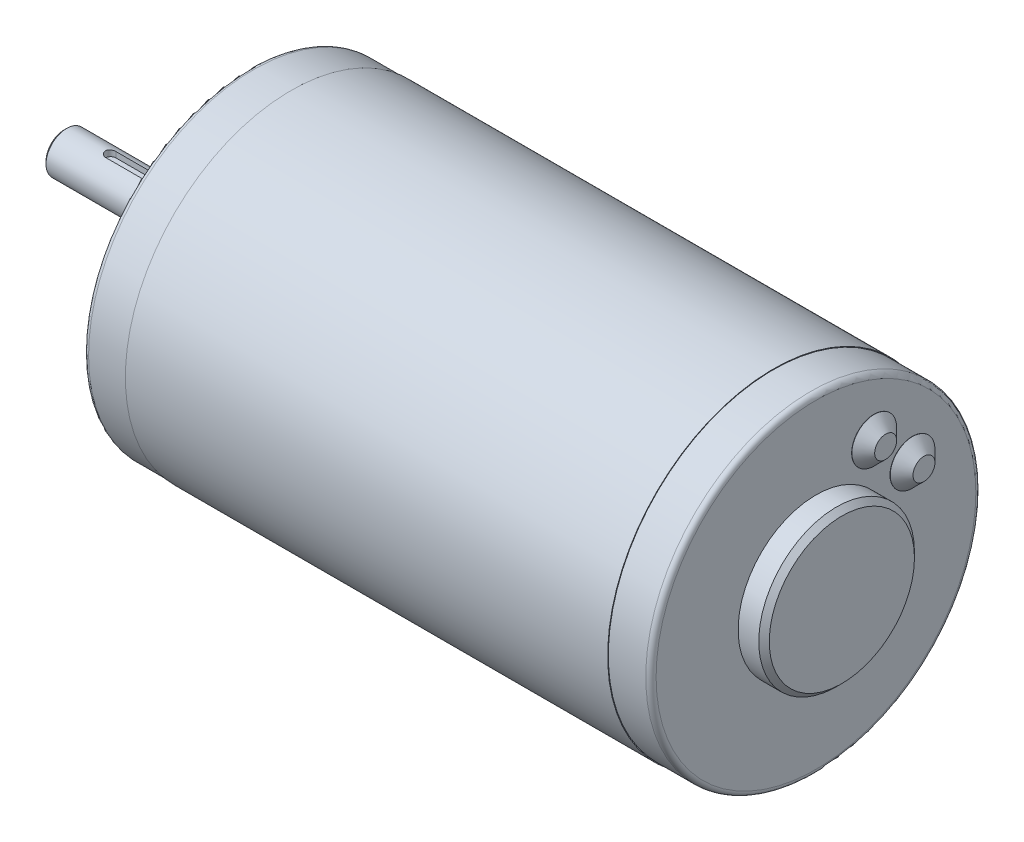
from build123d import *

# Parameters (mm, degrees)
SKETCH1_W                  = 93.1408
SKETCH1_H                  = 32.004
SKETCH2_R                  = 31.877
BOSS_EXTRUDE1_DEPTH        = 8.2296
SKETCH3_R                  = 15.0368
BOSS_EXTRUDE2_DEPTH        = 3.984
SKETCH4_R                  = 15.0368
BOSS_EXTRUDE3_DEPTH        = 1.016
BOSS_EXTRUDE3_TAPER        = 45
SKETCH5_R                  = 31.877
BOSS_EXTRUDE4_DEPTH        = 8.2296
SKETCH6_R                  = 9.525
BOSS_EXTRUDE5_DEPTH        = 4
SKETCH7_R                  = 4
BOSS_EXTRUDE6_DEPTH        = 31.6
CUT_EXTRUDE1_REACH         = 31.204
M3_5_CLEARANCE_HOLE1_D     = 4.0386
M3_5_CLEARANCE_HOLE1_DEPTH = 13.6144
M3_5_CLEARANCE_HOLE1_TIP   = 1.213317848
CHAMFER1_SIZE              = 1.016
CHAMFER2_SIZE              = 0.5
FILLET1_R                  = 1


with BuildPart() as part:
    # Sketch1 → Revolve1 (revolve)
    with BuildSketch(Plane.XY):
        with Locations((54.8, 16.002)):
            Rectangle(SKETCH1_W, SKETCH1_H)
    revolve(axis=Axis((8.2296, 0, 0), (1, 0, 0)))

    # Sketch2 → Boss-Extrude1 (add)
    with BuildSketch(Plane(origin=(101.3704, 0, 0), x_dir=(0, 0, -1), z_dir=(1, 0, 0))):
        Circle(SKETCH2_R)
    extrude(amount=BOSS_EXTRUDE1_DEPTH)

    # Sketch3 → Boss-Extrude2 (add)
    with BuildSketch(Plane(origin=(109.6, 0, 0), x_dir=(0, 0, -1), z_dir=(1, 0, 0))):
        Circle(SKETCH3_R)
    extrude(amount=BOSS_EXTRUDE2_DEPTH)

    # Sketch4 → Boss-Extrude3 (add)
    with BuildSketch(Plane(origin=(113.584, 0, 0), x_dir=(0, 0, -1), z_dir=(1, 0, 0))):
        Circle(SKETCH4_R)
    extrude(amount=BOSS_EXTRUDE3_DEPTH, taper=BOSS_EXTRUDE3_TAPER)

    # Sketch5 → Boss-Extrude4 (add)
    with BuildSketch(Plane.ZY.offset(-8.2296)):
        Circle(SKETCH5_R)
    extrude(amount=BOSS_EXTRUDE4_DEPTH)

    # Sketch6 → Boss-Extrude5 (add)
    with BuildSketch(Plane.ZY):
        Circle(SKETCH6_R)
    extrude(amount=BOSS_EXTRUDE5_DEPTH)

    # Sketch7 → Boss-Extrude6 (add)
    with BuildSketch(Plane.ZY.offset(4)):
        Circle(SKETCH7_R)
    extrude(amount=BOSS_EXTRUDE6_DEPTH)

    # Sketch8 → Cut-Extrude1 (cut, up to next)
    with BuildSketch(Plane.XZ.offset(-2.8), mode=Mode.PRIVATE) as cut_extrude1_sk1:
        with BuildLine():
            Line((-7.1, 1), (-26.6, 1))
            ThreePointArc((-26.6, 1), (-27.6, 0), (-26.6, -1))
            Line((-26.6, -1), (-7.1, -1))
            ThreePointArc((-7.1, -1), (-6.1, 0), (-7.1, 1))
        make_face()
    cut_extrude1_tool1 = extrude(cut_extrude1_sk1.sketch, amount=-CUT_EXTRUDE1_REACH, mode=Mode.PRIVATE) & part.part
    add(cut_extrude1_tool1.solids().sort_by_distance((-16.85, 2.8, 0))[0], mode=Mode.SUBTRACT)

    # Sketch9 → Revolve2 (revolve)
    with BuildSketch(Plane.XY.offset(-18.607090683)):
        Polygon((109.6, 15.525359639), (109.6, 11.207359639), (111.8479, 11.207359639), (111.8479, 13.325359639), (109.6479, 15.525359639), align=None)
    revolve(axis=Axis((109.6, 11.207359639, -18.607090683), (1, 0, 0)))

    # Sketch10 → Revolve3 (revolve)
    with BuildSketch(Plane.XY.offset(-11.207359639)):
        Polygon((109.6, 22.925090683), (109.6, 18.607090683), (111.8479, 18.607090683), (111.8479, 20.725090683), (109.6479, 22.925090683), align=None)
    revolve(axis=Axis((109.6, 18.607090683, -11.207359639), (1, 0, 0)))

    # M3.5 Clearance Hole1
    with Locations(Plane.ZY):
        with Locations((0, 25.4), (0, -25.4)):
            Hole(M3_5_CLEARANCE_HOLE1_D / 2, depth=M3_5_CLEARANCE_HOLE1_DEPTH)
            with Locations((0, 0, -(M3_5_CLEARANCE_HOLE1_DEPTH + M3_5_CLEARANCE_HOLE1_TIP / 2))):  # 118° drill point
                Cone(0, M3_5_CLEARANCE_HOLE1_D / 2, M3_5_CLEARANCE_HOLE1_TIP, mode=Mode.SUBTRACT)

    # Chamfer1
    chamfer1_edges = [part.edges().sort_by_distance(p)[0] for p in [
        (-4, 0, -9.525),
    ]]
    chamfer(chamfer1_edges, length=CHAMFER1_SIZE)

    # Chamfer2
    chamfer2_edges = [part.edges().sort_by_distance(p)[0] for p in [
        (-35.6, 0, -4),
    ]]
    chamfer(chamfer2_edges, length=CHAMFER2_SIZE)

    # Fillet1
    fillet1_edges = [part.edges().sort_by_distance(p)[0] for p in [
        (0, 0, -31.877),
        (109.6, 0, 31.877),
    ]]
    fillet(fillet1_edges, radius=FILLET1_R)


solid = part.part
